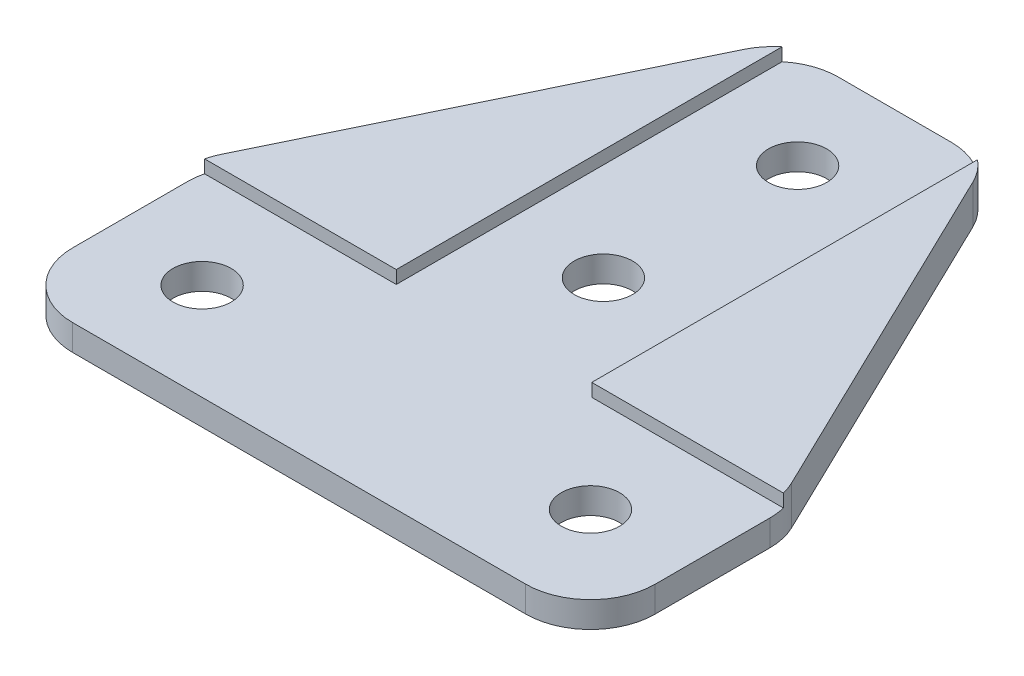
from build123d import *

# Parameters (mm, degrees)
EXTRUDE_1_DEPTH     = 3
SKETCH_2_R          = 2.25
CUT_EXTRUDE_1_DEPTH = 3
FILLET_1_R          = 5
CUT_EXTRUDE_2_DEPTH = 1


with BuildPart() as part:
    # ｽｹｯﾁ1 → ﾎﾞｽ - 押し出し1 (new body)
    with BuildSketch(Plane(origin=(0, 0, 0), x_dir=(1, 0, 0), z_dir=(0, 1, 0))):
        Polygon((0, 0), (45, 0), (45, 15), (30, 46), (15, 46), (0, 15), align=None)
    extrude(amount=EXTRUDE_1_DEPTH)

    # ｽｹｯﾁ2 → ｶｯﾄ - 押し出し1 (cut)
    with BuildSketch(Plane(origin=(0, 3, 0), x_dir=(1, 0, 0), z_dir=(0, 1, 0))):
        with Locations((7.5, 7.5)):
            Circle(SKETCH_2_R)
        with Locations((22.5, 38.5)):
            Circle(SKETCH_2_R)
        with Locations((22.5, 23.5)):
            Circle(SKETCH_2_R)
        with Locations((37.5, 7.5)):
            Circle(SKETCH_2_R)
    extrude(amount=-CUT_EXTRUDE_1_DEPTH, mode=Mode.SUBTRACT)

    # ﾌｨﾚｯﾄ1
    fillet_1_edges = [part.edges().sort_by_distance(p)[0] for p in [
        (0, 1.5, -15),
        (15, 1.5, -46),
        (30, 1.5, -46),
        (45, 1.5, -15),
        (45, 1.5, 0),
        (0, 1.5, 0),
    ]]
    fillet(fillet_1_edges, radius=FILLET_1_R)

    # ｽｹｯﾁ3 → ｶｯﾄ - 押し出し2 (cut)
    with BuildSketch(Plane(origin=(0, 3, 0), x_dir=(1, 0, 0), z_dir=(0, 1, 0))):
        Polygon((14.95, 46), (30.05, 46), (30.05, 15.05), (45, 15.05), (45, 0), (0, 0), (0, 15.05), (14.95, 15.05), align=None)
    extrude(amount=-CUT_EXTRUDE_2_DEPTH, mode=Mode.SUBTRACT)


solid = part.part
